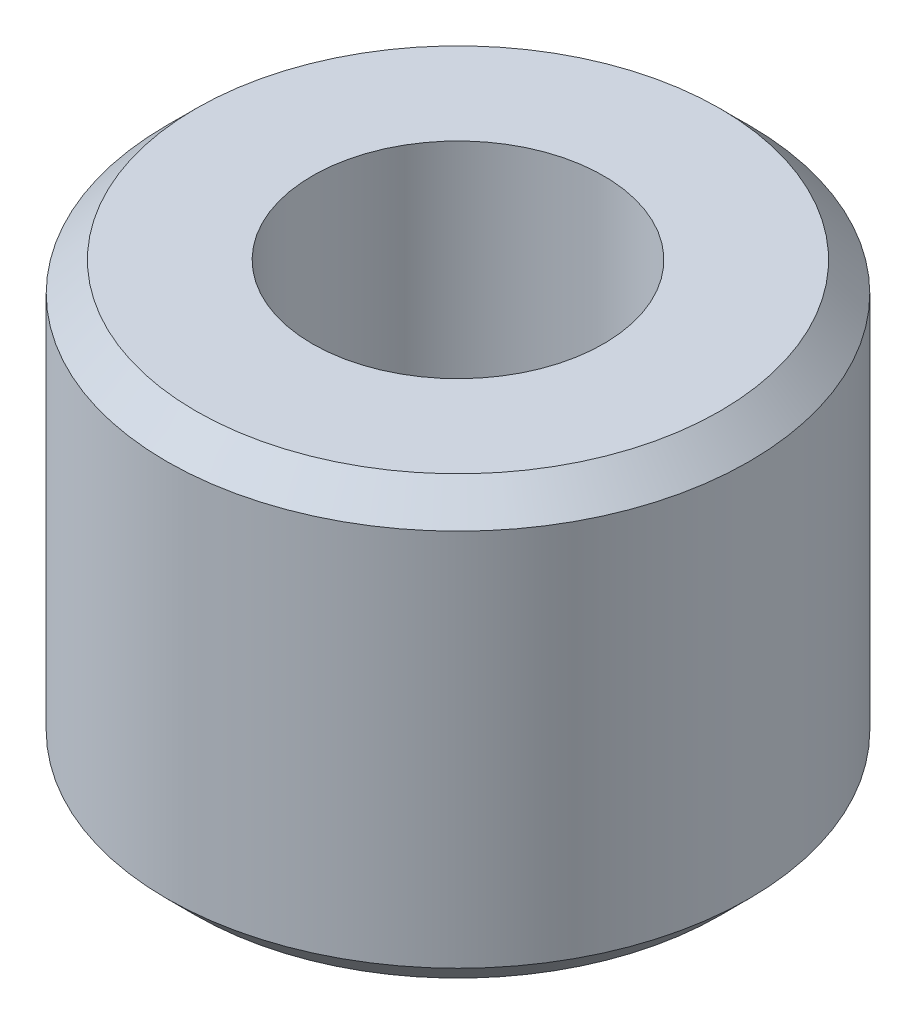
from build123d import *

# Parameters (mm, degrees)
SKETCH1_R           = 10
BOSS_EXTRUDE1_DEPTH = 15
SKETCH2_R           = 5
CUT_EXTRUDE1_DEPTH  = 15
CHAMFER1_SIZE       = 1


with BuildPart() as part:
    # Sketch1 → Boss-Extrude1 (new body)
    with BuildSketch(Plane(origin=(0, 0, 0), x_dir=(1, 0, 0), z_dir=(0, 1, 0))):
        Circle(SKETCH1_R)
    extrude(amount=BOSS_EXTRUDE1_DEPTH)

    # Sketch2 → Cut-Extrude1 (cut)
    with BuildSketch(Plane(origin=(0, 15, 0), x_dir=(1, 0, 0), z_dir=(0, 1, 0))):
        Circle(SKETCH2_R)
    extrude(amount=-CUT_EXTRUDE1_DEPTH, mode=Mode.SUBTRACT)

    # Chamfer1
    chamfer1_edges = [part.edges().sort_by_distance(p)[0] for p in [
        (-10, 0, 0),
        (-10, 15, 0),
    ]]
    chamfer(chamfer1_edges, length=CHAMFER1_SIZE)


solid = part.part
